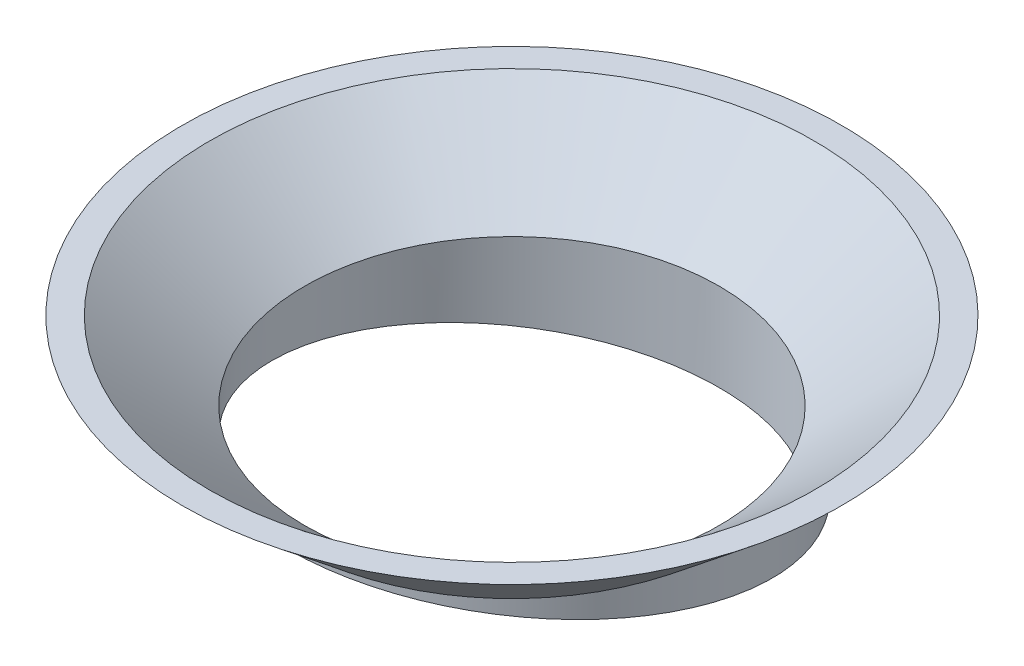
from build123d import *

# Parameters (mm, degrees)
ESQUISSE2_R             = 27.341483355
ENL_V_MAT_EXTRU_1_DEPTH = 57.620245699


with BuildPart() as part:
    # Esquisse1 → Révolution1 (revolve)
    with BuildSketch(Plane.XY):
        Polygon((26, 0), (26, 10), (38.146694728, 20), (35, 20), (24, 10.944038484), (24, 0), align=None)
    revolve(axis=Axis((0, 21, 0), (0, -1, 0)))

    # Esquisse2 → Enlèv. mat.-Extru.1 (cut, through all)
    with BuildSketch(Plane(origin=(0, 4.849231552, -0.855050358), x_dir=(-1, 0, 0), z_dir=(0, 0.984807753012208, -0.17364817766693072))):
        Circle(ESQUISSE2_R)
    extrude(amount=-ENL_V_MAT_EXTRU_1_DEPTH, mode=Mode.SUBTRACT)


solid = part.part
